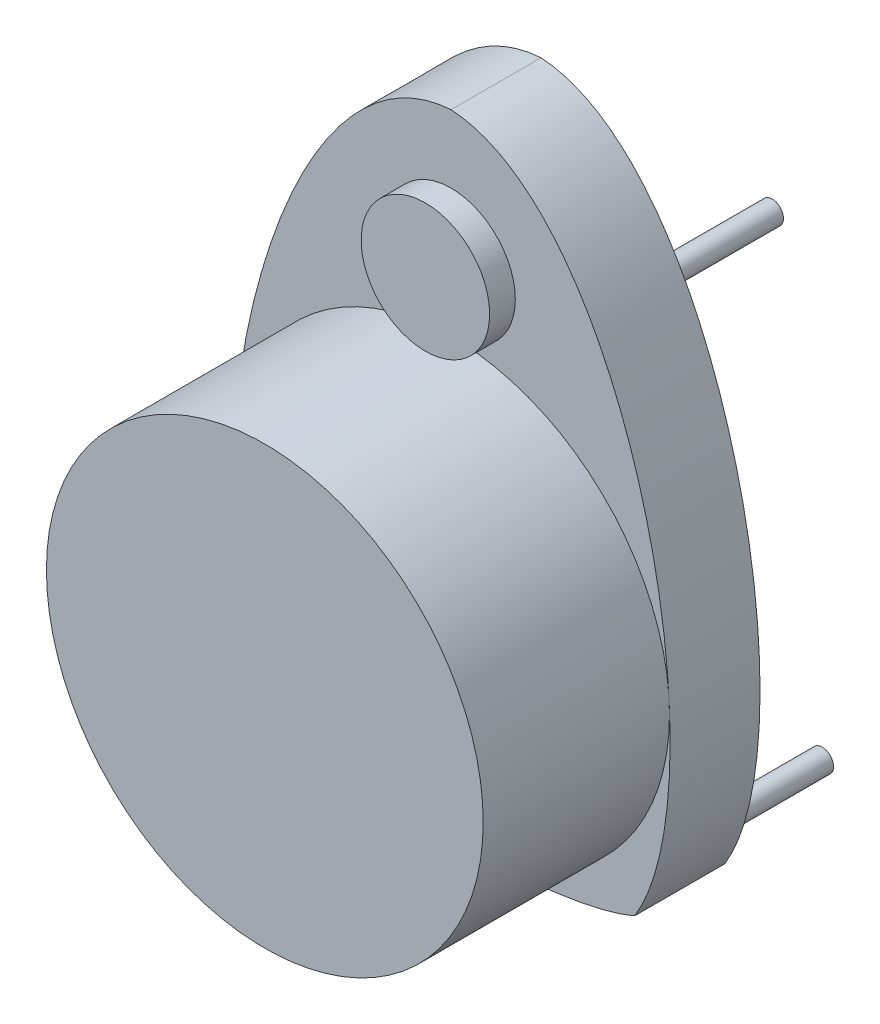
from build123d import *

# Parameters (mm, degrees)
SKETCH_1_R      = 34
EXTRUDE_2_DEPTH = 29
SKETCH_4_R      = 10
EXTRUDE_3_DEPTH = 4
EXTRUDE_5_DEPTH = 14
SKETCH_6_R      = 1.75
EXTRUDE_6_DEPTH = 16


with BuildPart() as part:
    # 草圖1 → 填料-伸長2 (new body)
    with BuildSketch(Plane.XY):
        Circle(SKETCH_1_R)
    extrude(amount=EXTRUDE_2_DEPTH)


with BuildPart() as body_2:
    # 草圖4 → 填料-伸長3 (new body)
    with BuildSketch(Plane.XY):
        with Locations((0, 44)):
            Circle(SKETCH_4_R)
    extrude(amount=EXTRUDE_3_DEPTH)


with BuildPart() as body_3:
    # 草圖5 → 填料-伸長5 (new body)
    with BuildSketch(Plane.XY):
        with BuildLine():
            add(Edge.make_bspline(
                [(0, 64.568950884), (-28.225840656, 62.766812112), (-42.774005852, -6.412874016), (-28.611317762, -29.803697061)],
                knots=[0, 0, 0, 0, 1, 1, 1, 1], degree=3))
            add(Edge.make_bspline(
                [(-28.611317762, -29.803697061), (-20.277297815, -33.507705927), (0, -34)],
                knots=[0, 0, 0, 1, 1, 1], degree=2))
            add(Edge.make_bspline(
                [(28.611317762, -29.803697061), (20.277297815, -33.507705927), (0, -34)],
                knots=[0, 0, 0, 1, 1, 1], degree=2))
            add(Edge.make_bspline(
                [(0, 64.568950884), (28.225840656, 62.766812112), (42.774005852, -6.412874016), (28.611317762, -29.803697061)],
                knots=[0, 0, 0, 0, 1, 1, 1, 1], degree=3))
        make_face()
    extrude(amount=-EXTRUDE_5_DEPTH)

    # 草圖6 → 填料-伸長6 (add)
    with BuildSketch(Plane(origin=(0, 0, -14), x_dir=(-1, 0, 0), z_dir=(0, 0, -1))):
        with Locations((-27.8, -24.231049116)):
            Circle(SKETCH_6_R)
        with Locations((27.8, -24.231049116)):
            Circle(SKETCH_6_R)
        with Locations((-20, 45.768950884)):
            Circle(SKETCH_6_R)
        with Locations((20, 45.768950884)):
            Circle(SKETCH_6_R)
    extrude(amount=EXTRUDE_6_DEPTH)


solid = Compound([part.part, body_2.part, body_3.part])
